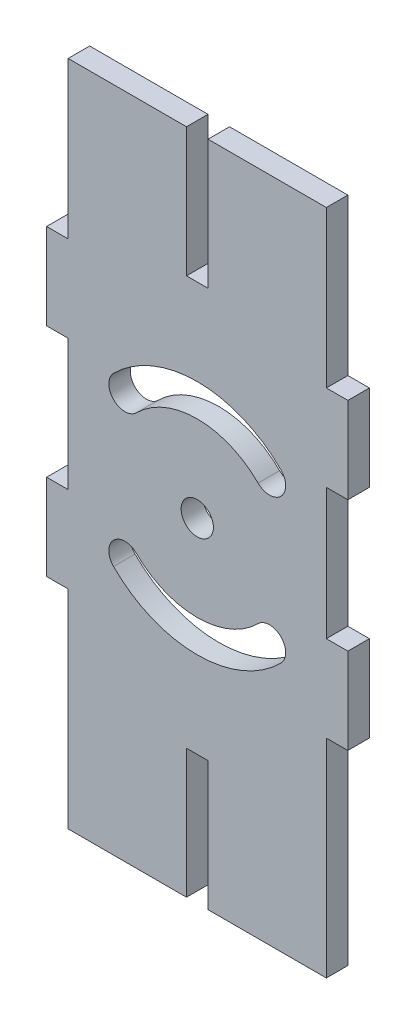
from build123d import *

# Parameters (mm, degrees)
BOSS_EXTRUDE1_DEPTH = 3.175
SKETCH3_R           = 2.38125
CUT_EXTRUDE1_DEPTH  = 5.08
SKETCH5_W           = 3.175
SKETCH5_H           = 12.7
BOSS_EXTRUDE2_DEPTH = 3.175


with BuildPart() as part:
    # Sketch1 → Boss-Extrude1 (new body)
    with BuildSketch(Plane.XY):
        Polygon((-38.1, 365.778475051), (-20.6375, 365.778475051), (-20.6375, 346.728475051), (-17.4625, 346.728475051), (-17.4625, 365.778475051), (0, 365.778475051), (0, 267.318840011), (-17.4625, 267.318840011), (-17.4625, 286.368840011), (-20.6375, 286.368840011), (-20.6375, 267.318840011), (-38.1, 267.318840011), align=None)
    extrude(amount=BOSS_EXTRUDE1_DEPTH)

    # Sketch3 → Cut-Extrude1 (cut)
    with BuildSketch(Plane.XY.offset(3.175)):
        with Locations((-19.05, 316.548657531)):
            Circle(SKETCH3_R)
        with BuildLine():
            ThreePointArc((-31.397852166, 304.200805365), (-19.05, 299.086157531), (-6.702147834, 304.200805365))
            ThreePointArc((-6.702147834, 304.200805365), (-6.702147834, 307.56840141), (-10.069743879, 307.56840141))
            ThreePointArc((-10.069743879, 307.56840141), (-19.05, 303.848657531), (-28.030256121, 307.56840141))
            ThreePointArc((-28.030256121, 307.56840141), (-31.397852166, 307.56840141), (-31.397852166, 304.200805365))
        make_face()
        with BuildLine():
            ThreePointArc((-6.702147834, 328.896509698), (-19.05, 334.011157531), (-31.397852166, 328.896509698))
            ThreePointArc((-31.397852166, 328.896509698), (-31.397852166, 325.528913652), (-28.030256121, 325.528913652))
            ThreePointArc((-28.030256121, 325.528913652), (-19.05, 329.248657531), (-10.069743879, 325.528913652))
            ThreePointArc((-10.069743879, 325.528913652), (-6.702147834, 325.528913652), (-6.702147834, 328.896509698))
        make_face()
    extrude(amount=-CUT_EXTRUDE1_DEPTH, mode=Mode.SUBTRACT)

    # Sketch5 → Boss-Extrude2 (add)
    with BuildSketch(Plane.XY.offset(3.175)):
        with Locations((1.5875, 336.36769286)):
            Rectangle(SKETCH5_W, SKETCH5_H)
        with Locations((1.5875, 304.329924583)):
            Rectangle(SKETCH5_W, SKETCH5_H)
        with Locations((-39.6875, 304.329924583)):
            Rectangle(SKETCH5_W, SKETCH5_H)
        with Locations((-39.6875, 336.36769286)):
            Rectangle(SKETCH5_W, SKETCH5_H)
    extrude(amount=-BOSS_EXTRUDE2_DEPTH)


solid = part.part
